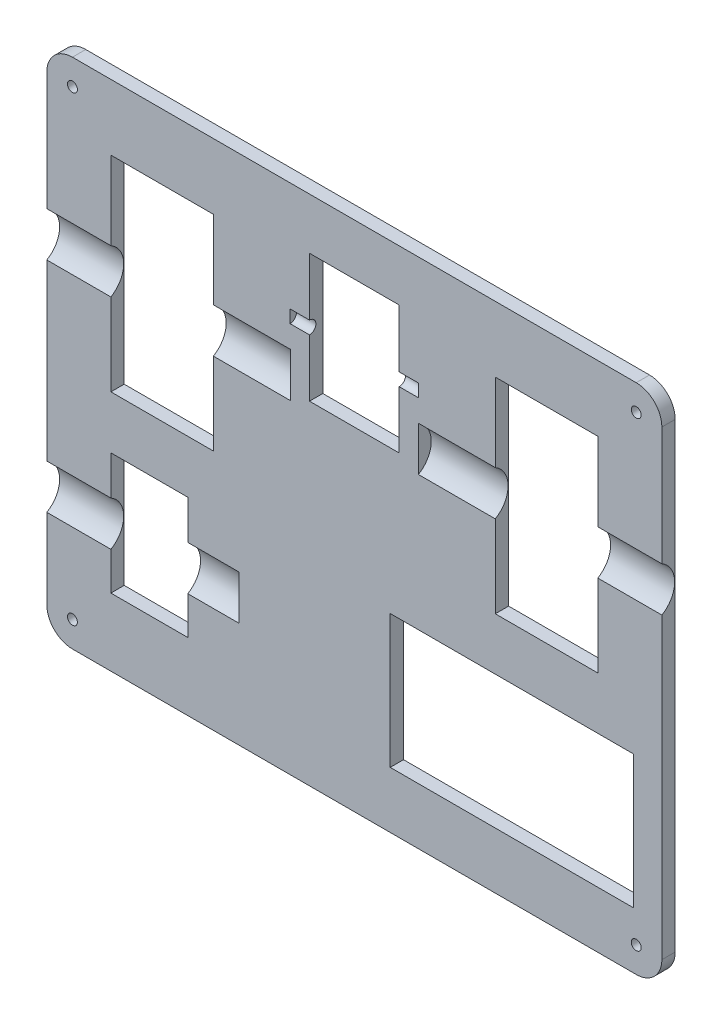
from build123d import *

# Parameters (mm, degrees)
SKETCH1_W                                         = 304.8
SKETCH1_H                                         = 254
BOSS_EXTRUDE1_DEPTH                               = 6.604
FILLET1_R                                         = 12.7
SKETCH6_W                                         = 50.8
SKETCH6_H                                         = 101.6
SKETCH6_W_2                                       = 44.45
SKETCH6_H_2                                       = 63.5
SKETCH6_W_3                                       = 38.1
SKETCH6_H_3                                       = 60.198
SKETCH6_W_4                                       = 120.65
SKETCH6_H_4                                       = 66.04
CUT_EXTRUDE1_DEPTH                                = 7.62
CUT_EXTRUDE2_DEPTH                                = 120.65
CUT_EXTRUDE3_DEPTH                                = 95.25
CUT_EXTRUDE4_DEPTH                                = 9.652
CSK_FOR_8_FLAT_HEAD_MACHINE_SCREW_100_D           = 4.9149
CSK_FOR_8_FLAT_HEAD_MACHINE_SCREW_100_DEPTH       = 10.668
CSK_FOR_8_FLAT_HEAD_MACHINE_SCREW_100_CSINK_D     = 8.4328
CSK_FOR_8_FLAT_HEAD_MACHINE_SCREW_100_CSINK_ANGLE = 100
CSK_FOR_8_FLAT_HEAD_MACHINE_SCREW_100_TIP         = 1.476584928


with BuildPart() as part:
    # Sketch1 → Boss-Extrude1 (new body)
    with BuildSketch(Plane.XY):
        Rectangle(SKETCH1_W, SKETCH1_H)
    extrude(amount=BOSS_EXTRUDE1_DEPTH)

    # Fillet1
    fillet1_edges = [part.edges().sort_by_distance(p)[0] for p in [
        (-152.4, 127, 3.302),
        (152.4, 127, 3.302),
        (152.4, -127, 3.302),
        (-152.4, -127, 3.302),
    ]]
    fillet(fillet1_edges, radius=FILLET1_R)

    # Sketch6 → Cut-Extrude1 (cut)
    with BuildSketch(Plane.XY.offset(6.604)):
        with Locations((-95.25, 43.688)):
            Rectangle(SKETCH6_W, SKETCH6_H)
        with Locations((0, 69.85)):
            Rectangle(SKETCH6_W_2, SKETCH6_H_2)
        with Locations((-101.6, -63.373)):
            Rectangle(SKETCH6_W_3, SKETCH6_H_3)
        with Locations((95.25, 43.688)):
            Rectangle(SKETCH6_W, SKETCH6_H)
        with Locations((78.105, -66.04)):
            Rectangle(SKETCH6_W_4, SKETCH6_H_4)
    extrude(amount=-CUT_EXTRUDE1_DEPTH, mode=Mode.SUBTRACT)

    # Sketch9 → Cut-Extrude2 (cut)
    with BuildSketch(Plane.ZY.offset(152.4)):
        with BuildLine():
            Line((6.604, 55.626), (6.604, 33.628954744))
            ThreePointArc((6.604, 33.628954744), (0.254, 44.627477372), (6.604, 55.626))
        make_face()
    cut_extrude2 = extrude(amount=-CUT_EXTRUDE2_DEPTH, mode=Mode.SUBTRACT)

    # Mirror1: Cut-Extrude2 across plane
    add(cut_extrude2.mirror(Plane(origin=(0, 0, 0), x_dir=(0, 0, 1), z_dir=(1, 0, 0))), mode=Mode.SUBTRACT)

    # Sketch10 → Cut-Extrude3 (cut)
    with BuildSketch(Plane.ZY.offset(152.4)):
        with BuildLine():
            Line((6.604, -52.678954744), (6.604, -74.676))
            ThreePointArc((6.604, -74.676), (0.254, -63.677477372), (6.604, -52.678954744))
        make_face()
    extrude(amount=-CUT_EXTRUDE3_DEPTH, mode=Mode.SUBTRACT)

    # Sketch11 → Cut-Extrude4 (cut)
    with BuildSketch(Plane.ZY.offset(-22.225)):
        with BuildLine():
            Line((6.604, 72.898), (6.604, 66.548))
            ThreePointArc((6.604, 66.548), (3.429, 69.723), (6.604, 72.898))
        make_face()
    cut_extrude4 = extrude(amount=-CUT_EXTRUDE4_DEPTH, mode=Mode.SUBTRACT)

    # Mirror2: Cut-Extrude4 across plane
    add(cut_extrude4.mirror(Plane(origin=(0, 0, 0), x_dir=(0, 0, 1), z_dir=(1, 0, 0))), mode=Mode.SUBTRACT)

    # CSK for #8 Flat Head Machine Screw (100)1
    with Locations(Plane(origin=(0, 0, 0), x_dir=(-1, 0, 0), z_dir=(0, 0, -1))):
        with Locations((-139.7, 114.3), (139.7, 114.3), (139.7, -114.3), (-139.7, -114.3)):
            CounterSinkHole(CSK_FOR_8_FLAT_HEAD_MACHINE_SCREW_100_D / 2, CSK_FOR_8_FLAT_HEAD_MACHINE_SCREW_100_CSINK_D / 2, depth=CSK_FOR_8_FLAT_HEAD_MACHINE_SCREW_100_DEPTH, counter_sink_angle=CSK_FOR_8_FLAT_HEAD_MACHINE_SCREW_100_CSINK_ANGLE)
            with Locations((0, 0, -(CSK_FOR_8_FLAT_HEAD_MACHINE_SCREW_100_DEPTH + CSK_FOR_8_FLAT_HEAD_MACHINE_SCREW_100_TIP / 2))):  # 118° drill point
                Cone(0, CSK_FOR_8_FLAT_HEAD_MACHINE_SCREW_100_D / 2, CSK_FOR_8_FLAT_HEAD_MACHINE_SCREW_100_TIP, mode=Mode.SUBTRACT)


solid = part.part
